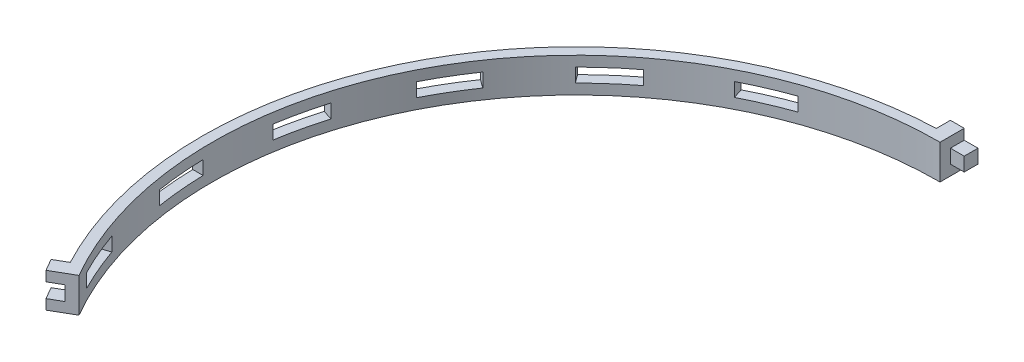
from build123d import *

# Parameters (mm, degrees)
BOSS_EXTRUDE1_DEPTH             = 10
SKETCH2_W                       = 8
SKETCH2_H                       = 4.2
CUT_EXTRUDE1_DEPTH              = 4
SKETCH3_W                       = 8
SKETCH3_H                       = 4
BOSS_EXTRUDE2_DEPTH             = 4
SKETCH4_W                       = 14
SKETCH4_H                       = 4
CUT_EXTRUDE2_DEPTH              = 109.5
CIRPATTERN4_COUNT               = 5
CIRPATTERN4_ANGLE               = 72
CIRPATTERN4_THE_OTHER_WAY_COUNT = 5
CIRPATTERN4_THE_OTHER_WAY_ANGLE = 72


with BuildPart() as part:
    # Sketch1 → Boss-Extrude1 (new body)
    with BuildSketch(Plane(origin=(0, 0, 0), x_dir=(1, 0, 0), z_dir=(0, 1, 0))):
        with BuildLine():
            Line((-4, 112.5), (-4, 108.426242211))
            ThreePointArc((-4, 108.426242211), (-93.963756311, 54.25), (-95.899880192, -50.74901949))
            Line((-95.899880192, -50.74901949), (-99.427857926, -52.785898385))
            Line((-99.427857926, -52.785898385), (-97.427857926, -56.25))
            Line((-97.427857926, -56.25), (-91.365680099, -52.75))
            ThreePointArc((-91.365680099, -52.75), (-91.365680099, 52.75), (0, 105.5))
            Line((0, 105.5), (0, 112.5))
            Line((0, 112.5), (-4, 112.5))
        make_face()
    extrude(amount=BOSS_EXTRUDE1_DEPTH)

    # Sketch2 → Cut-Extrude1 (cut)
    with BuildSketch(Plane(origin=(-97.427857926, 0, 56.25), x_dir=(0.5, 0, 0.866025404), z_dir=(-0.866025404, 0, 0.5))):
        with Locations((0, 5)):
            Rectangle(SKETCH2_W, SKETCH2_H)
    extrude(amount=-CUT_EXTRUDE1_DEPTH, mode=Mode.SUBTRACT)

    # Sketch3 → Boss-Extrude2 (add)
    with BuildSketch(Plane(origin=(0, 0, -112.5), x_dir=(-1, 0, 0), z_dir=(0, 0, -1))):
        with Locations((0, 5)):
            Rectangle(SKETCH3_W, SKETCH3_H)
    extrude(amount=-BOSS_EXTRUDE2_DEPTH)

    # Sketch4 → Cut-Extrude2 (cut, through all)
    with BuildSketch(Plane(origin=(0, 0, 0), x_dir=(0, 0, -1), z_dir=(1, 0, 0))):
        with Locations((-9.672320837, 5)):
            Rectangle(SKETCH4_W, SKETCH4_H)
    cut_extrude2 = extrude(amount=-CUT_EXTRUDE2_DEPTH, mode=Mode.SUBTRACT)

    # CirPattern4: Cut-Extrude2 ×5 about axis
    cirpattern4_axis = Axis((0, 0, 0), (0, -1, 0))
    for i in range(1, CIRPATTERN4_COUNT):
        add(cut_extrude2.rotate(cirpattern4_axis, i * CIRPATTERN4_ANGLE / (CIRPATTERN4_COUNT - 1)), mode=Mode.SUBTRACT)

    # CirPattern4 the other way: Cut-Extrude2 ×5 about axis
    cirpattern4_the_other_way_axis = Axis((0, 0, 0), (0, 1, 0))
    for i in range(1, CIRPATTERN4_THE_OTHER_WAY_COUNT):
        add(cut_extrude2.rotate(cirpattern4_the_other_way_axis, i * CIRPATTERN4_THE_OTHER_WAY_ANGLE / (CIRPATTERN4_THE_OTHER_WAY_COUNT - 1)), mode=Mode.SUBTRACT)


solid = part.part
